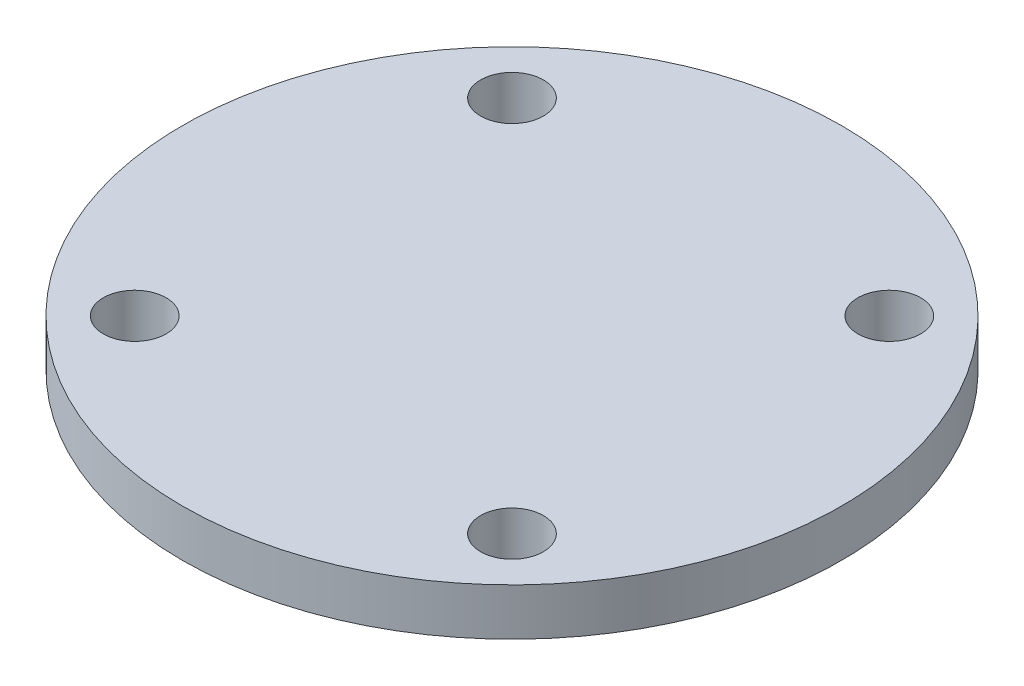
from build123d import *

# Parameters (mm, degrees)
SKETCH1_R                = 21
SKETCH1_R_2              = 12
SKETCH1_R_3              = 2
BOSS_EXTRUDE1_DEPTH      = 3
BOSS_EXTRUDE2_DEPTH      = 3
BOSS_EXTRUDE2_DEPTH_BACK = 1
SKETCH1_2_R              = 12


with BuildPart() as part:
    # Sketch1 → Boss-Extrude1 (new body)
    with BuildSketch(Plane(origin=(0, 0, 0), x_dir=(1, 0, 0), z_dir=(0, 1, 0))):
        Circle(SKETCH1_R)
        Circle(SKETCH1_R_2, mode=Mode.SUBTRACT)
        with Locations((-12.02081528, 12.02081528)):
            Circle(SKETCH1_R_3, mode=Mode.SUBTRACT)
        with Locations((12.02081528, 12.02081528)):
            Circle(SKETCH1_R_3, mode=Mode.SUBTRACT)
        with Locations((12.02081528, -12.02081528)):
            Circle(SKETCH1_R_3, mode=Mode.SUBTRACT)
        with Locations((-12.02081528, -12.02081528)):
            Circle(SKETCH1_R_3, mode=Mode.SUBTRACT)
    extrude(amount=BOSS_EXTRUDE1_DEPTH)

    # Sketch1_2 → Boss-Extrude2 (add, two sides: drawn at the far end of the back side and taken through both)
    with BuildSketch(Plane(origin=(0, 0, 0), x_dir=(1, 0, 0), z_dir=(0, 1, 0)).offset(-BOSS_EXTRUDE2_DEPTH_BACK)):
        Circle(SKETCH1_2_R)
    extrude(amount=BOSS_EXTRUDE2_DEPTH + BOSS_EXTRUDE2_DEPTH_BACK)


solid = part.part
